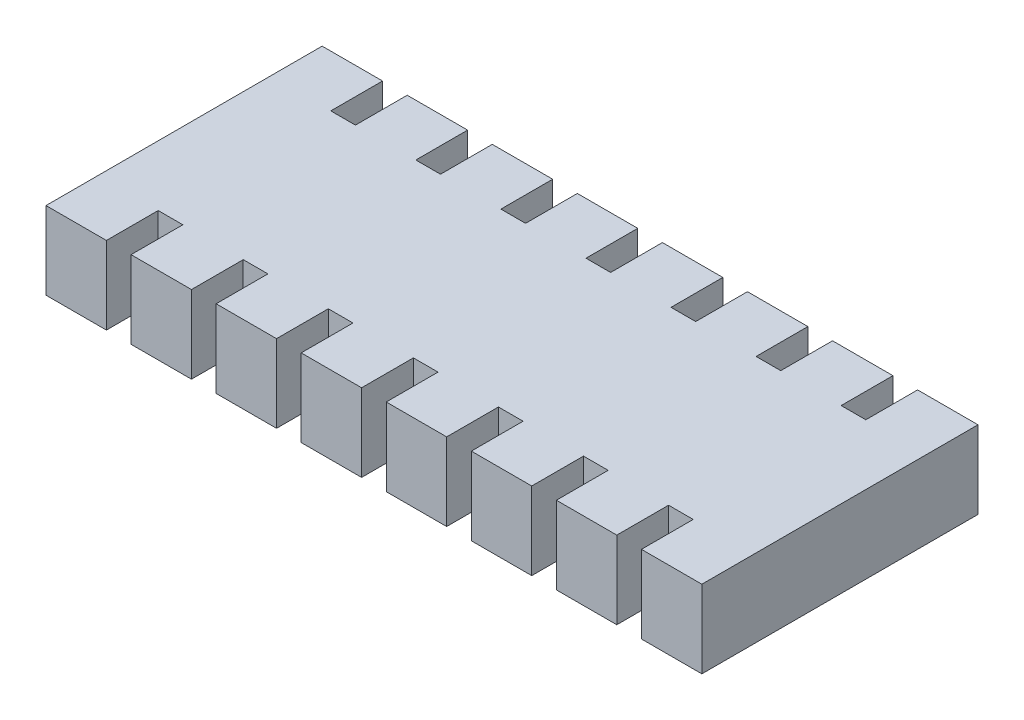
from build123d import *

# Parameters (mm, degrees)
SKETCH1_W           = 3.8
SKETCH1_H           = 1
BOSS_EXTRUDE1_DEPTH = 0.45
SKETCH2_W           = 0.35
SKETCH2_H           = 0.3
BOSS_EXTRUDE2_DEPTH = 0.45


with BuildPart() as part:
    # Sketch1 → Boss-Extrude1 (new body)
    with BuildSketch(Plane(origin=(0, 0, 0), x_dir=(1, 0, 0), z_dir=(0, 1, 0))):
        Rectangle(SKETCH1_W, SKETCH1_H)
    extrude(amount=BOSS_EXTRUDE1_DEPTH)

    # Sketch2 → Boss-Extrude2 (add)
    with BuildSketch(Plane(origin=(0, 0.45, 0), x_dir=(1, 0, 0), z_dir=(0, 1, 0))):
        with Locations((-1.232142857, 0.65)):
            Rectangle(SKETCH2_W, SKETCH2_H)
        with Locations((-1.725, 0.65)):
            Rectangle(SKETCH2_W, SKETCH2_H)
        with Locations((-0.739285714, 0.65)):
            Rectangle(SKETCH2_W, SKETCH2_H)
        with Locations((-0.246428571, 0.65)):
            Rectangle(SKETCH2_W, SKETCH2_H)
        with Locations((0.246428571, 0.65)):
            Rectangle(SKETCH2_W, SKETCH2_H)
        with Locations((0.739285714, 0.65)):
            Rectangle(SKETCH2_W, SKETCH2_H)
        with Locations((1.232142857, 0.65)):
            Rectangle(SKETCH2_W, SKETCH2_H)
        with Locations((1.725, 0.65)):
            Rectangle(SKETCH2_W, SKETCH2_H)
        with Locations((1.725, -0.65)):
            Rectangle(SKETCH2_W, SKETCH2_H)
        with Locations((1.232142857, -0.65)):
            Rectangle(SKETCH2_W, SKETCH2_H)
        with Locations((0.739285714, -0.65)):
            Rectangle(SKETCH2_W, SKETCH2_H)
        with Locations((0.246428571, -0.65)):
            Rectangle(SKETCH2_W, SKETCH2_H)
        with Locations((-0.246428571, -0.65)):
            Rectangle(SKETCH2_W, SKETCH2_H)
        with Locations((-0.739285714, -0.65)):
            Rectangle(SKETCH2_W, SKETCH2_H)
        with Locations((-1.232142857, -0.65)):
            Rectangle(SKETCH2_W, SKETCH2_H)
        with Locations((-1.725, -0.65)):
            Rectangle(SKETCH2_W, SKETCH2_H)
    extrude(amount=-BOSS_EXTRUDE2_DEPTH)


solid = part.part
